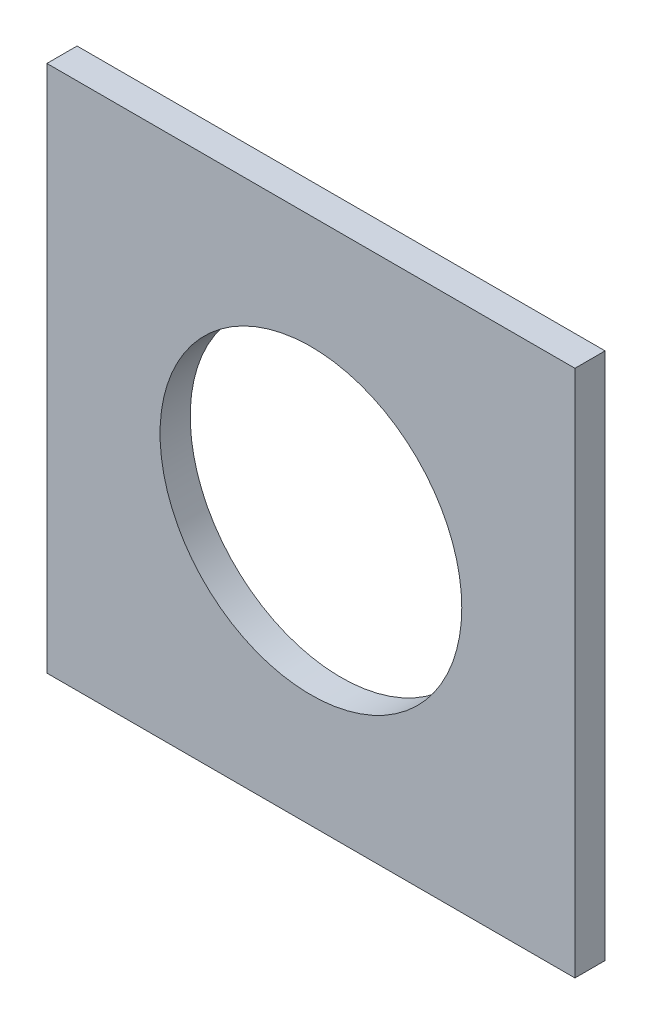
from build123d import *

# Parameters (mm, degrees)
CROQUIS1_W              = 700
CROQUIS1_H              = 700
SALIENTE_EXTRUIR1_DEPTH = 40
CROQUIS2_R              = 200
CORTAR_EXTRUIR1_DEPTH   = 41


with BuildPart() as part:
    # Croquis1 → Saliente-Extruir1 (new body)
    with BuildSketch(Plane.XY):
        Rectangle(CROQUIS1_W, CROQUIS1_H)
    extrude(amount=SALIENTE_EXTRUIR1_DEPTH)

    # Croquis2 → Cortar-Extruir1 (cut, through all)
    with BuildSketch(Plane.XY.offset(40)):
        Circle(CROQUIS2_R)
    extrude(amount=-CORTAR_EXTRUIR1_DEPTH, mode=Mode.SUBTRACT)


solid = part.part
